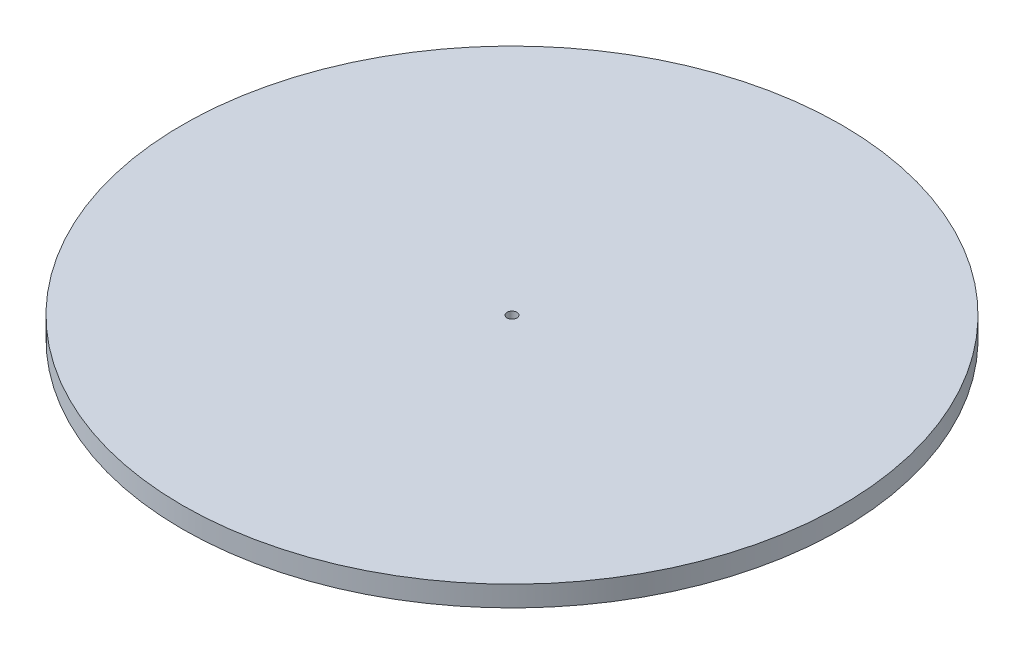
from build123d import *

# Parameters (mm, degrees)
SKETCH1_R           = 50.8
SKETCH1_R_2         = 0.762
BOSS_EXTRUDE1_DEPTH = 3.175


with BuildPart() as part:
    # Sketch1 → Boss-Extrude1 (new body)
    with BuildSketch(Plane(origin=(0, 0, 0), x_dir=(1, 0, 0), z_dir=(0, 1, 0))):
        Circle(SKETCH1_R)
        Circle(SKETCH1_R_2, mode=Mode.SUBTRACT)
    extrude(amount=-BOSS_EXTRUDE1_DEPTH)


solid = part.part
